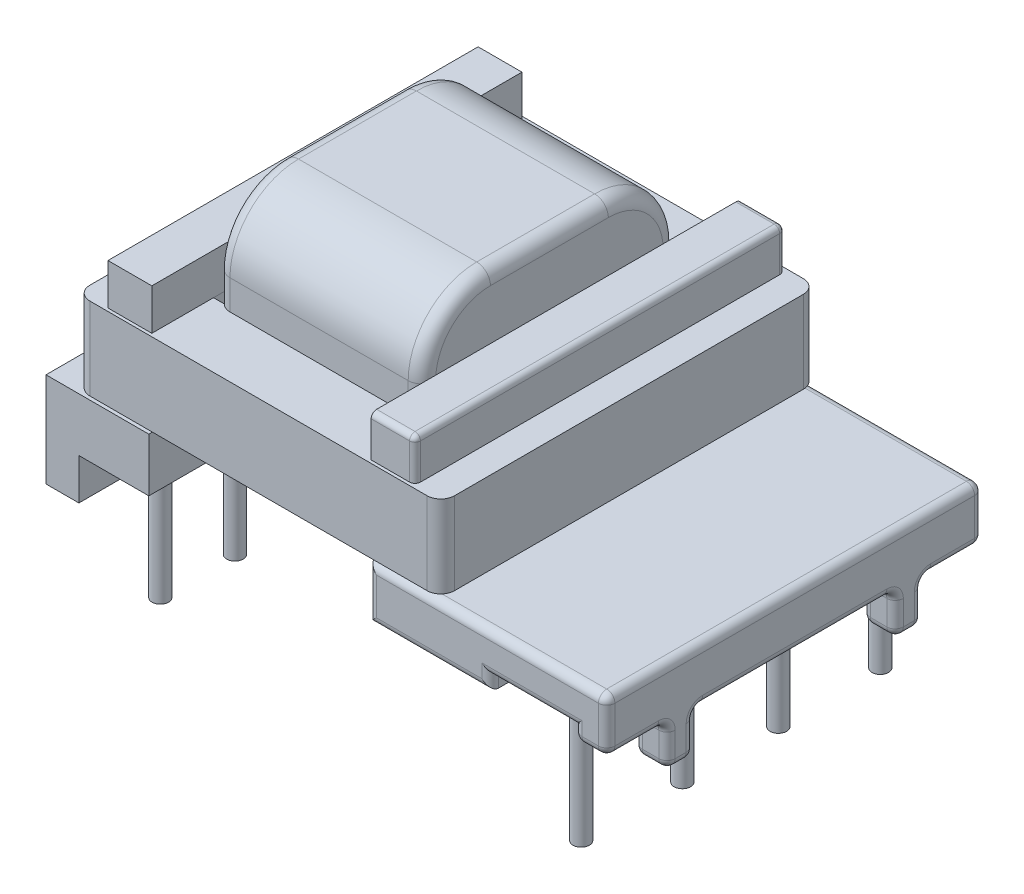
from build123d import *

# Parameters (mm, degrees)
SKETCH1_R                  = 0.3
BOSS_EXTRUDE1_DEPTH        = 3
BOSS_EXTRUDE1_DEPTH_BACK   = 2.92
BOSS_EXTRUDE1_2_DEPTH      = 3
BOSS_EXTRUDE1_2_DEPTH_BACK = 2.92
BOSS_EXTRUDE1_3_DEPTH      = 3
BOSS_EXTRUDE1_3_DEPTH_BACK = 2.92
BOSS_EXTRUDE1_4_DEPTH      = 3
BOSS_EXTRUDE1_4_DEPTH_BACK = 2.92
BOSS_EXTRUDE1_5_DEPTH      = 3
BOSS_EXTRUDE1_5_DEPTH_BACK = 2.92
BOSS_EXTRUDE1_6_DEPTH      = 3
BOSS_EXTRUDE1_6_DEPTH_BACK = 2.92
BOSS_EXTRUDE1_7_DEPTH      = 3
BOSS_EXTRUDE1_7_DEPTH_BACK = 2.92
BOSS_EXTRUDE1_8_DEPTH      = 3
BOSS_EXTRUDE1_8_DEPTH_BACK = 2.92
BOSS_EXTRUDE1_9_DEPTH      = 3
BOSS_EXTRUDE1_9_DEPTH_BACK = 2.92
SKETCH2_W                  = 20.45
SKETCH2_H                  = 3.45
BOSS_EXTRUDE2_DEPTH        = 6.86
CUT_EXTRUDE1_DEPTH         = 18.573318554
SKETCH4_W                  = 2.2
SKETCH4_H                  = 1.5
SKETCH4_W_2                = 7.32
CUT_EXTRUDE2_DEPTH         = 2
SKETCH5_W                  = 10.52
SKETCH5_H                  = 1.5
CUT_EXTRUDE3_DEPTH         = 2
SKETCH6_W                  = 8
SKETCH6_H                  = 5
CUT_EXTRUDE4_DEPTH         = 18.573318554
BOSS_EXTRUDE3_DEPTH        = 3.75
SKETCH8_W                  = 13.3
SKETCH8_H                  = 13.72
SKETCH8_W_2                = 8
SKETCH8_H_2                = 9
BOSS_EXTRUDE4_DEPTH        = 1.5
SKETCH9_W                  = 1.6
SKETCH9_H                  = 1.5
BOSS_EXTRUDE5_DEPTH        = 6.75
BOSS_EXTRUDE5_2_DEPTH      = 6.75
SKETCH10_R                 = 0.3
SKETCH10_R_2               = 0.301088965
BOSS_EXTRUDE6_DEPTH        = 2
FILLET1_R                  = 0.3
FILLET2_R                  = 0.2
FILLET3_R                  = 0.5
FILLET4_R                  = 0.5


with BuildPart() as part:
    # Sketch1 → Boss-Extrude1 (new, two sides)
    with BuildSketch(Plane(origin=(0, 0, 0), x_dir=(1, 0, 0), z_dir=(0, 1, 0))) as boss_extrude1_sk:
        with Locations(Location((-7.675, -5.44, 0), (0, 0, 270))):
            Circle(SKETCH1_R)
    extrude(amount=BOSS_EXTRUDE1_DEPTH)
    extrude(boss_extrude1_sk.sketch, amount=-BOSS_EXTRUDE1_DEPTH_BACK)



with BuildPart() as body_2:
    # Sketch1 → Boss-Extrude1 2 (new, two sides)
    with BuildSketch(Plane(origin=(0, 0, 0), x_dir=(1, 0, 0), z_dir=(0, 1, 0))) as boss_extrude1_2_sk:
        with Locations(Location((-7.675, -2.72, 0), (0, 0, 270))):
            Circle(SKETCH1_R)
    extrude(amount=BOSS_EXTRUDE1_2_DEPTH)
    extrude(boss_extrude1_2_sk.sketch, amount=-BOSS_EXTRUDE1_2_DEPTH_BACK)


with BuildPart() as body_3:
    # Sketch1 → Boss-Extrude1 3 (new, two sides)
    with BuildSketch(Plane(origin=(0, 0, 0), x_dir=(1, 0, 0), z_dir=(0, 1, 0))) as boss_extrude1_3_sk:
        with Locations(Location((-7.675, 0, 0), (0, 0, 270))):
            Circle(SKETCH1_R)
    extrude(amount=BOSS_EXTRUDE1_3_DEPTH)
    extrude(boss_extrude1_3_sk.sketch, amount=-BOSS_EXTRUDE1_3_DEPTH_BACK)


with BuildPart() as body_4:
    # Sketch1 → Boss-Extrude1 4 (new, two sides)
    with BuildSketch(Plane(origin=(0, 0, 0), x_dir=(1, 0, 0), z_dir=(0, 1, 0))) as boss_extrude1_4_sk:
        with Locations(Location((-7.675, 5.47, 0), (0, 0, 270))):
            Circle(SKETCH1_R)
    extrude(amount=BOSS_EXTRUDE1_4_DEPTH)
    extrude(boss_extrude1_4_sk.sketch, amount=-BOSS_EXTRUDE1_4_DEPTH_BACK)


with BuildPart() as body_5:
    # Sketch1 → Boss-Extrude1 5 (new, two sides)
    with BuildSketch(Plane(origin=(0, 0, 0), x_dir=(1, 0, 0), z_dir=(0, 1, 0))) as boss_extrude1_5_sk:
        with Locations(Location((-7.675, 2.72, 0), (0, 0, 270))):
            Circle(SKETCH1_R)
    extrude(amount=BOSS_EXTRUDE1_5_DEPTH)
    extrude(boss_extrude1_5_sk.sketch, amount=-BOSS_EXTRUDE1_5_DEPTH_BACK)


with BuildPart() as body_6:
    # Sketch1 → Boss-Extrude1 6 (new, two sides)
    with BuildSketch(Plane(origin=(0, 0, 0), x_dir=(1, 0, 0), z_dir=(0, 1, 0))) as boss_extrude1_6_sk:
        with Locations(Location((7.675, 5.47, 0), (0, 0, 270))):
            Circle(SKETCH1_R)
    extrude(amount=BOSS_EXTRUDE1_6_DEPTH)
    extrude(boss_extrude1_6_sk.sketch, amount=-BOSS_EXTRUDE1_6_DEPTH_BACK)


with BuildPart() as body_7:
    # Sketch1 → Boss-Extrude1 7 (new, two sides)
    with BuildSketch(Plane(origin=(0, 0, 0), x_dir=(1, 0, 0), z_dir=(0, 1, 0))) as boss_extrude1_7_sk:
        with Locations(Location((7.675, 1.75, 0), (0, 0, 270))):
            Circle(SKETCH1_R)
    extrude(amount=BOSS_EXTRUDE1_7_DEPTH)
    extrude(boss_extrude1_7_sk.sketch, amount=-BOSS_EXTRUDE1_7_DEPTH_BACK)


with BuildPart() as body_8:
    # Sketch1 → Boss-Extrude1 8 (new, two sides)
    with BuildSketch(Plane(origin=(0, 0, 0), x_dir=(1, 0, 0), z_dir=(0, 1, 0))) as boss_extrude1_8_sk:
        with Locations(Location((7.675, -1.75, 0), (0, 0, 270))):
            Circle(SKETCH1_R)
    extrude(amount=BOSS_EXTRUDE1_8_DEPTH)
    extrude(boss_extrude1_8_sk.sketch, amount=-BOSS_EXTRUDE1_8_DEPTH_BACK)


with BuildPart() as body_9:
    # Sketch1 → Boss-Extrude1 9 (new, two sides)
    with BuildSketch(Plane(origin=(0, 0, 0), x_dir=(1, 0, 0), z_dir=(0, 1, 0))) as boss_extrude1_9_sk:
        with Locations(Location((7.675, -5.44, 0), (0, 0, 270))):
            Circle(SKETCH1_R)
    extrude(amount=BOSS_EXTRUDE1_9_DEPTH)
    extrude(boss_extrude1_9_sk.sketch, amount=-BOSS_EXTRUDE1_9_DEPTH_BACK)


with BuildPart() as part_1:
    add(part.part)

    add(body_2.part)  # Boss-Extrude2 merges body 2

    add(body_3.part)  # Boss-Extrude2 merges body 3

    add(body_4.part)  # Boss-Extrude2 merges body 4

    add(body_5.part)  # Boss-Extrude2 merges body 5

    add(body_6.part)  # Boss-Extrude2 merges body 6

    add(body_7.part)  # Boss-Extrude2 merges body 7

    add(body_8.part)  # Boss-Extrude2 merges body 8

    add(body_9.part)  # Boss-Extrude2 merges body 9
    # Sketch2 → Boss-Extrude2 (add, symmetric)
    with BuildSketch(Plane.XY):
        with Locations((-0.2, 1.725)):
            Rectangle(SKETCH2_W, SKETCH2_H)
    extrude(amount=BOSS_EXTRUDE2_DEPTH, both=True)

    # Sketch3 → Cut-Extrude1 (cut, through all)
    with BuildSketch(Plane.XY.offset(6.86)):
        Polygon((-9.225, 0), (-9.225, 1.5), (5.775, 1.5), (5.775, 2), (8.825, 2), (8.825, 0), align=None)
    extrude(amount=-CUT_EXTRUDE1_DEPTH, mode=Mode.SUBTRACT)


with BuildPart() as cut_extrude1_piece_1:
    # of the separate pieces the step leaves, piece 1, a body of its own (cut_extrude1_pieces)
    add(part_1.part.solids().sort_by_distance((10.025, 0, 6.86))[0])

    # Sketch4 → Cut-Extrude2 (cut)
    with BuildSketch(Plane(origin=(10.025, 0, 0), x_dir=(0, 0, -1), z_dir=(1, 0, 0))):
        with Locations((-5.76, 0.75)):
            Rectangle(SKETCH4_W, SKETCH4_H)
        with Locations((0, 0.75)):
            Rectangle(SKETCH4_W_2, SKETCH4_H)
        with Locations((5.76, 0.75)):
            Rectangle(SKETCH4_W, SKETCH4_H)
    extrude(amount=-CUT_EXTRUDE2_DEPTH, mode=Mode.SUBTRACT)

    # Sketch5 → Cut-Extrude3 (cut)
    with BuildSketch(Plane.ZY.offset(10.425)):
        with Locations((0, 0.75)):
            Rectangle(SKETCH5_W, SKETCH5_H)
    extrude(amount=-CUT_EXTRUDE3_DEPTH, mode=Mode.SUBTRACT)

    # Sketch6 → Cut-Extrude4 (cut, through all)
    with BuildSketch(Plane.XY.offset(6.86)):
        with Locations((-2.675, 2.5)):
            Rectangle(SKETCH6_W, SKETCH6_H)
    extrude(amount=-CUT_EXTRUDE4_DEPTH, mode=Mode.SUBTRACT)


with BuildPart() as cut_extrude1_piece_2:
    # of the separate pieces the step leaves, piece 2, a body of its own (cut_extrude1_pieces)
    add(part_1.part.solids().sort_by_distance((7.675, 0, -5.17))[0])



with BuildPart() as cut_extrude1_piece_3:
    # of the separate pieces the step leaves, piece 3, a body of its own (cut_extrude1_pieces)
    add(part_1.part.solids().sort_by_distance((7.675, 0, -1.45))[0])


with BuildPart() as cut_extrude1_piece_4:
    # of the separate pieces the step leaves, piece 4, a body of its own (cut_extrude1_pieces)
    add(part_1.part.solids().sort_by_distance((7.675, 0, 2.05))[0])


with BuildPart() as cut_extrude1_piece_5:
    # of the separate pieces the step leaves, piece 5, a body of its own (cut_extrude1_pieces)
    add(part_1.part.solids().sort_by_distance((-7.675, 0, -2.42))[0])


with BuildPart() as cut_extrude1_piece_6:
    # of the separate pieces the step leaves, piece 6, a body of its own (cut_extrude1_pieces)
    add(part_1.part.solids().sort_by_distance((-7.675, 0, 0.3))[0])


with BuildPart() as cut_extrude1_piece_7:
    # of the separate pieces the step leaves, piece 7, a body of its own (cut_extrude1_pieces)
    add(part_1.part.solids().sort_by_distance((-7.675, 0, 3.02))[0])


with BuildPart() as cut_extrude1_piece_8:
    # of the separate pieces the step leaves, piece 8, a body of its own (cut_extrude1_pieces)
    add(part_1.part.solids().sort_by_distance((7.675, 0, 5.74))[0])


with BuildPart() as cut_extrude1_piece_9:
    # of the separate pieces the step leaves, piece 9, a body of its own (cut_extrude1_pieces)
    add(part_1.part.solids().sort_by_distance((-7.675, 0, 5.74))[0])


with BuildPart() as cut_extrude1_piece_10:
    # of the separate pieces the step leaves, piece 10, a body of its own (cut_extrude1_pieces)
    add(part_1.part.solids().sort_by_distance((-7.675, 0, -5.17))[0])


with BuildPart() as cut_extrude4_piece_1:
    # of the separate pieces the step leaves, piece 1, a body of its own (cut_extrude4_pieces)
    add(cut_extrude1_piece_1.part.solids().sort_by_distance((10.025, 0, 4.66))[0])


with BuildPart() as cut_extrude4_piece_2:
    # of the separate pieces the step leaves, piece 2, a body of its own (cut_extrude4_pieces)
    add(cut_extrude1_piece_1.part.solids().sort_by_distance((-9.225, 0, 6.86))[0])


with BuildPart() as body_12:
    # Sketch7 → Boss-Extrude3 (new, symmetric)
    with BuildSketch(Plane(origin=(-2.675, 0, 0), x_dir=(0, 0, -1), z_dir=(1, 0, 0))):
        with BuildLine():
            Line((-2.15, 10.16), (2.15, 10.16))
            ThreePointArc((2.15, 10.16), (3.917766953, 9.427766953), (4.65, 7.66))
            Line((4.65, 7.66), (4.65, 2.5))
            ThreePointArc((4.65, 2.5), (3.917766953, 0.732233047), (2.15, 0))
            Line((2.15, 0), (-2.15, 0))
            ThreePointArc((-2.15, 0), (-3.917766953, 0.732233047), (-4.65, 2.5))
            Line((-4.65, 2.5), (-4.65, 7.66))
            ThreePointArc((-4.65, 7.66), (-3.917766953, 9.427766953), (-2.15, 10.16))
        make_face()
    extrude(amount=BOSS_EXTRUDE3_DEPTH, both=True)

    # Fillet4
    fillet4_edges = [body_12.edges().sort_by_distance(p)[0] for p in [
        (1.075, 9.427766953, 3.917766953),
        (-6.425, 10.16, 0),
        (-6.425, 9.427766953, -3.917766953),
        (1.075, 5.08, 4.65),
        (1.075, 0.732233047, 3.917766953),
        (1.075, 0, 0),
        (1.075, 0.732233047, -3.917766953),
        (1.075, 5.08, -4.65),
        (1.075, 9.427766953, -3.917766953),
        (1.075, 10.16, 0),
        (-6.425, 5.08, -4.65),
        (-6.425, 0.732233047, -3.917766953),
        (-6.425, 0, 0),
        (-6.425, 0.732233047, 3.917766953),
        (-6.425, 5.08, 4.65),
        (-6.425, 9.427766953, 3.917766953),
    ]]
    fillet(fillet4_edges, radius=FILLET4_R)


with BuildPart() as body_13:
    # Sketch8 → Boss-Extrude4 (new, symmetric)
    with BuildSketch(Plane(origin=(0, 5.08, 0), x_dir=(1, 0, 0), z_dir=(0, 1, 0))):
        with Locations((-2.675, 0)):
            Rectangle(SKETCH8_W, SKETCH8_H)
        with Locations((-2.675, 0)):
            Rectangle(SKETCH8_W_2, SKETCH8_H_2, mode=Mode.SUBTRACT)
    extrude(amount=BOSS_EXTRUDE4_DEPTH, both=True)

    # Fillet3
    fillet3_edges = [body_13.edges().sort_by_distance(p)[0] for p in [
        (-9.325, 5.08, -6.86),
        (3.975, 5.08, -6.86),
        (3.975, 5.08, 6.86),
        (-9.325, 5.08, 6.86),
    ]]
    fillet(fillet3_edges, radius=FILLET3_R)


with BuildPart() as body_14:
    # Sketch9 → Boss-Extrude5 (new, symmetric)
    with BuildSketch(Plane.XY):
        with Locations((2.125, 7.33)):
            Rectangle(SKETCH9_W, SKETCH9_H)
    extrude(amount=BOSS_EXTRUDE5_DEPTH, both=True)

    # Fillet2
    fillet2_edges = [body_14.edges().sort_by_distance(p)[0] for p in [
        (2.925, 7.33, 6.75),
        (2.125, 8.08, 6.75),
        (2.125, 8.08, -6.75),
        (2.925, 7.33, -6.75),
        (2.925, 8.08, 0),
    ]]
    fillet(fillet2_edges, radius=FILLET2_R)


with BuildPart() as body_15:
    # Sketch9 → Boss-Extrude5 2 (new, symmetric)
    with BuildSketch(Plane.XY):
        with Locations((-7.475, 7.33)):
            Rectangle(SKETCH9_W, SKETCH9_H)
    extrude(amount=BOSS_EXTRUDE5_2_DEPTH, both=True)


with BuildPart() as cut_extrude1_piece_2_1:
    add(cut_extrude1_piece_2.part)

    add(cut_extrude1_piece_3.part)  # Boss-Extrude6 merges Cut-Extrude1 piece 3

    add(cut_extrude1_piece_4.part)  # Boss-Extrude6 merges Cut-Extrude1 piece 4

    add(cut_extrude1_piece_5.part)  # Boss-Extrude6 merges Cut-Extrude1 piece 5

    add(cut_extrude1_piece_6.part)  # Boss-Extrude6 merges Cut-Extrude1 piece 6

    add(cut_extrude1_piece_7.part)  # Boss-Extrude6 merges Cut-Extrude1 piece 7

    add(cut_extrude1_piece_8.part)  # Boss-Extrude6 merges Cut-Extrude1 piece 8

    add(cut_extrude1_piece_9.part)  # Boss-Extrude6 merges Cut-Extrude1 piece 9

    add(cut_extrude1_piece_10.part)  # Boss-Extrude6 merges Cut-Extrude1 piece 10

    add(cut_extrude4_piece_1.part)  # Boss-Extrude6 merges Cut-Extrude4 piece 1

    add(cut_extrude4_piece_2.part)  # Boss-Extrude6 merges Cut-Extrude4 piece 2
    # Sketch10 → Boss-Extrude6 (add)
    with BuildSketch(Plane(origin=(0, 0, 0), x_dir=(1, 0, 0), z_dir=(0, 1, 0))):
        with Locations(Location((7.675, -5.44, 0), (0, 0, 270))):
            Circle(SKETCH10_R)
        with Locations(Location((7.675, -1.75, 0), (0, 0, 270))):
            Circle(SKETCH10_R)
        with Locations(Location((7.675, 1.75, 0), (0, 0, 270))):
            Circle(SKETCH10_R)
        with Locations(Location((7.675, 5.47, 0), (0, 0, 180))):
            Circle(SKETCH10_R)
        with Locations(Location((-7.675, 5.47, 0), (0, 0, 270))):
            Circle(SKETCH10_R)
        with Locations(Location((-7.675, 2.72, 0), (0, 0, 270))):
            Circle(SKETCH10_R)
        with Locations(Location((-7.675, 0, 0), (0, 0, 270))):
            Circle(SKETCH10_R)
        with Locations(Location((-7.675, -2.72, 0), (0, 0, 270))):
            Circle(SKETCH10_R_2)
        with Locations(Location((-7.675, -5.44, 0), (0, 0, 270))):
            Circle(SKETCH10_R)
    extrude(amount=BOSS_EXTRUDE6_DEPTH)

    # Fillet1
    fillet1_edges = [cut_extrude1_piece_2_1.edges().sort_by_distance(p)[0] for p in [
        (9.425, 1.5, 4.66),
        (10.025, 1.5, 5.76),
        (9.425, 0, 4.66),
        (10.025, 0.75, 4.66),
        (9.425, 1.5, 3.66),
        (10.025, 0.75, 3.66),
        (9.425, 1.5, -3.66),
        (10.025, 1.5, 0),
        (9.425, 0, -3.66),
        (10.025, 0.75, -3.66),
        (9.425, 1.5, -4.66),
        (10.025, 0.75, -4.66),
        (9.425, 1.5, -6.86),
        (10.025, 1.5, -5.76),
        (1.325, 2.475, 6.86),
        (7.3, 2, 6.86),
        (9.425, 0, 3.66),
        (10.025, 0, -4.16),
        (10.025, 2.475, -6.86),
        (10.025, 0, 4.16),
        (5.675, 3.45, -6.86),
        (10.025, 3.45, 0),
        (3.55, 1.5, -6.86),
        (1.325, 2.475, -6.86),
        (8.825, 1.75, -6.86),
        (7.3, 2, -6.86),
        (5.775, 1.75, -6.86),
        (9.425, 1.5, 6.86),
        (10.025, 2.475, 6.86),
        (5.675, 3.45, 6.86),
        (9.425, 0, -4.66),
        (8.825, 1.5, -5.76),
        (8.825, 0.75, -4.66),
        (8.825, 0, -4.16),
        (8.825, 0.75, -3.66),
        (8.825, 1.5, 0),
        (8.825, 0.75, 3.66),
        (8.825, 0, 4.16),
        (8.825, 0.75, 4.66),
        (8.825, 1.5, 5.76),
        (8.825, 1.75, 6.86),
        (5.775, 1.75, 6.86),
        (3.55, 1.5, 6.86),
    ]]
    fillet(fillet1_edges, radius=FILLET1_R)


solid = Compound([body_12.part, body_13.part, body_14.part, body_15.part, cut_extrude1_piece_2_1.part])
